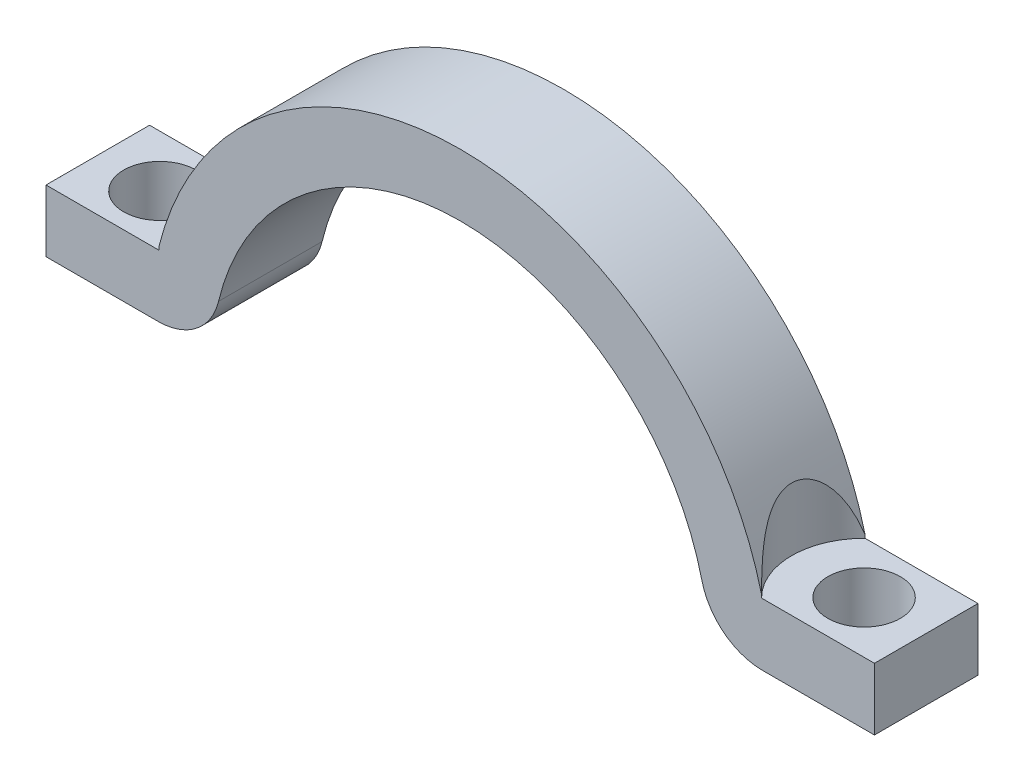
from build123d import *

# Parameters (mm, degrees)
BOSS_EXTRU_2_DEPTH      = 5
ESQUISSE3_R             = 1.75
ENL_V_MAT_EXTRU_2_DEPTH = 4
ESQUISSE4_R             = 3.5
ENL_V_MAT_EXTRU_3_DEPTH = 12.5


with BuildPart() as part:
    # Esquisse1 → Boss.-Extru.2 (new body)
    with BuildSketch(Plane.XY):
        with BuildLine():
            Line((-20, 0.5), (-14.585952146, 0.5))
            ThreePointArc((-14.585952146, 0.5), (-12.728534584, 1.144156202), (-11.668761717, 2.8))
            ThreePointArc((-11.668761717, 2.8), (0, 12), (11.668761717, 2.8))
            ThreePointArc((11.668761717, 2.8), (12.728534584, 1.144156202), (14.585952146, 0.5))
            Line((14.585952146, 0.5), (20, 0.5))
            Line((20, 0.5), (20, 3.5))
            Line((20, 3.5), (14.585952146, 3.5))
            ThreePointArc((14.585952146, 3.5), (0, 15), (-14.585952146, 3.5))
            Line((-14.585952146, 3.5), (-20, 3.5))
            Line((-20, 3.5), (-20, 0.5))
        make_face()
    extrude(amount=BOSS_EXTRU_2_DEPTH)

    # Esquisse3 → Enlèv. mat.-Extru.2 (cut, through all)
    with BuildSketch(Plane(origin=(0, 3.5, 0), x_dir=(1, 0, 0), z_dir=(0, 1, 0))):
        with Locations((-17, -2.5)):
            Circle(ESQUISSE3_R)
        with Locations((17, -2.5)):
            Circle(ESQUISSE3_R)
    extrude(amount=-ENL_V_MAT_EXTRU_2_DEPTH, mode=Mode.SUBTRACT)

    # Esquisse4 → Enlèv. mat.-Extru.3 (cut, through all)
    with BuildSketch(Plane(origin=(0, 3.5, 0), x_dir=(1, 0, 0), z_dir=(0, 1, 0))):
        with Locations((-17, -2.5)):
            Circle(ESQUISSE4_R)
        with Locations((17, -2.5)):
            Circle(ESQUISSE4_R)
    extrude(amount=ENL_V_MAT_EXTRU_3_DEPTH, mode=Mode.SUBTRACT)


solid = part.part
